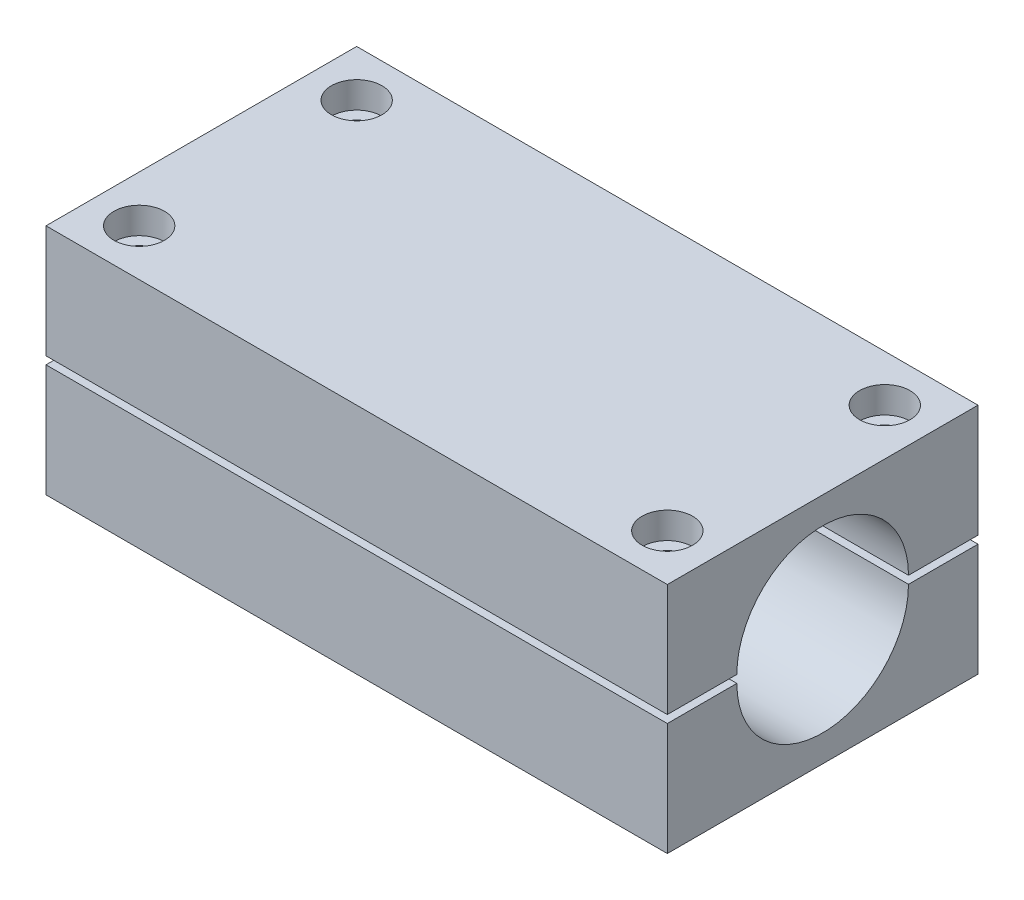
from build123d import *

# Parameters (mm, degrees)
CROQUIS1_W                                           = 80
CROQUIS1_H                                           = 40
SALIENTE_EXTRUIR1_DEPTH                              = 30
CORTAR_EXTRUIR1_DEPTH                                = 81
CROQUIS3_W                                           = 40
CROQUIS3_H                                           = 1
CORTAR_EXTRUIR2_DEPTH                                = 81
REFRENTADO_PARA_TORNILLO_CON_CABEZA_HUEC_D           = 3.4
REFRENTADO_PARA_TORNILLO_CON_CABEZA_HUEC_CBORE_D     = 6.5
REFRENTADO_PARA_TORNILLO_CON_CABEZA_HUEC_CBORE_DEPTH = 3.4
CORTAR_EXTRUIR4_DEPTH                                = 3
MATRIZL1_COUNT                                       = 2
MATRIZL1_PITCH                                       = 68
MATRIZL1_COUNT_DIR2                                  = 2
MATRIZL1_PITCH_DIR2                                  = 28


with BuildPart() as part:
    # Croquis1 → Saliente-Extruir1 (new body)
    with BuildSketch(Plane(origin=(0, 0, 0), x_dir=(1, 0, 0), z_dir=(0, 1, 0))):
        Rectangle(CROQUIS1_W, CROQUIS1_H)
    extrude(amount=SALIENTE_EXTRUIR1_DEPTH)

    # Croquis2 → Cortar-Extruir1 (cut, through all)
    with BuildSketch(Plane.ZY.offset(40)):
        with BuildLine():
            Line((-11.05, 14.5), (11.05, 14.5))
            ThreePointArc((11.05, 14.5), (0, 3.45), (-11.05, 14.5))
        make_face()
        with BuildLine():
            Line((11.05, 15.5), (-11.05, 15.5))
            ThreePointArc((-11.05, 15.5), (0, 26.55), (11.05, 15.5))
        make_face()
    extrude(amount=-CORTAR_EXTRUIR1_DEPTH, mode=Mode.SUBTRACT)

    # Croquis3 → Cortar-Extruir2 (cut, through all)
    with BuildSketch(Plane.ZY.offset(40)):
        with Locations((0, 15)):
            Rectangle(CROQUIS3_W, CROQUIS3_H)
    extrude(amount=-CORTAR_EXTRUIR2_DEPTH, mode=Mode.SUBTRACT)

    # Refrentado para tornillo con cabeza hueca de M31 (through all)
    with Locations(Plane(origin=(0, 30, 0), x_dir=(1, 0, 0), z_dir=(0, 1, 0))):
        with Locations((-34, 14), (-34, -14), (34, 14), (34, -14)):
            CounterBoreHole(REFRENTADO_PARA_TORNILLO_CON_CABEZA_HUEC_D / 2, REFRENTADO_PARA_TORNILLO_CON_CABEZA_HUEC_CBORE_D / 2, REFRENTADO_PARA_TORNILLO_CON_CABEZA_HUEC_CBORE_DEPTH)

    # Croquis9 → Cortar-Extruir4 (cut)
    with BuildSketch(Plane.XZ):
        Polygon((-30.545509036, 14.25786077), (-32.496068495, 17.120607317), (-35.95055946, 16.862746547), (-37.454490964, 13.74213923), (-35.503931505, 10.879392683), (-32.04944054, 11.137253453), align=None)
    cortar_extruir4 = extrude(amount=-CORTAR_EXTRUIR4_DEPTH, mode=Mode.SUBTRACT)

    # MatrizL1: Cortar-Extruir4 2 × 2
    with Locations(*[(i * MATRIZL1_PITCH, 0, -j * MATRIZL1_PITCH_DIR2) for i in range(MATRIZL1_COUNT) for j in range(MATRIZL1_COUNT_DIR2) if (i, j) != (0, 0)]):
        add(cortar_extruir4, mode=Mode.SUBTRACT)


solid = part.part
